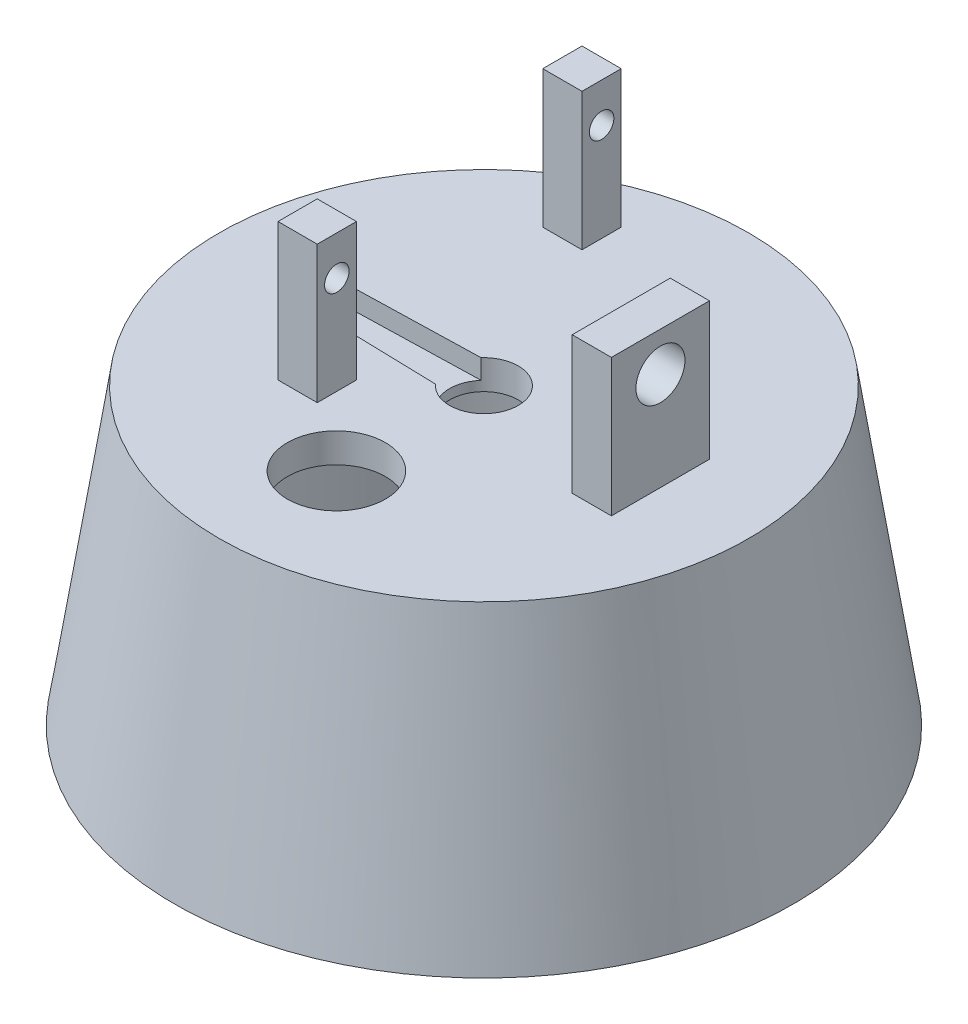
from build123d import *

# Parameters (mm, degrees)
SKETCH_1_R          = 27
SKETCH_1_R_2        = 25.25
EXTRUDE_1_DEPTH     = 27
SKETCH_3_R          = 27
SKETCH_3_R_2        = 2.4
EXTRUDE_2_DEPTH     = 3
SKETCH_7_W          = 4
SKETCH_7_H          = 4
EXTRUDE_3_DEPTH     = 14
SKETCH_8_R          = 1.25
CUT_EXTRUDE_1_DEPTH = 14
SKETCH_10_W         = 4
SKETCH_10_H         = 10
EXTRUDE_4_DEPTH     = 14
SKETCH_11_R         = 2.5
CUT_EXTRUDE_3_DEPTH = 14
SKETCH_12_R         = 5
CUT_EXTRUDE_4_DEPTH = 14
SKETCH_13_R         = 2.4
CUT_EXTRUDE_5_DEPTH = 2
SKETCH_14_R         = 2.4
CUT_EXTRUDE_6_DEPTH = 91


with BuildPart() as part:
    # 草图1 → 凸台-拉伸1 (new body)
    with BuildSketch(Plane(origin=(0, 0, 0), x_dir=(1, 0, 0), z_dir=(0, 1, 0))):
        Circle(SKETCH_1_R)
        Circle(SKETCH_1_R_2, mode=Mode.SUBTRACT)
    extrude(amount=EXTRUDE_1_DEPTH)

    # 草图3 → 凸台-拉伸2 (add)
    with BuildSketch(Plane(origin=(0, 27, 0), x_dir=(1, 0, 0), z_dir=(0, 1, 0))):
        Circle(SKETCH_3_R)
        Circle(SKETCH_3_R_2, mode=Mode.SUBTRACT)
    extrude(amount=EXTRUDE_2_DEPTH)

    # 草图5 → 旋转2 (revolve)
    with BuildSketch(Plane.XY):
        Polygon((27, 30), (31.564027788, 0), (27, 0), align=None)
    revolve(axis=Axis((0, 0, 0), (0, 1, 0)))

    # 草图7 → 凸台-拉伸3 (add)
    with BuildSketch(Plane(origin=(0, 30, 0), x_dir=(1, 0, 0), z_dir=(0, 1, 0))):
        with Locations((-9, 19)):
            Rectangle(SKETCH_7_W, SKETCH_7_H)
        with Locations((-9, -8)):
            Rectangle(SKETCH_7_W, SKETCH_7_H)
    extrude(amount=EXTRUDE_3_DEPTH)

    # 草图8 → 切除-拉伸1 (cut)
    with BuildSketch(Plane(origin=(-7, 0, 0), x_dir=(0, 0, -1), z_dir=(1, 0, 0))):
        with Locations((-8, 40)):
            Circle(SKETCH_8_R)
        with Locations((19, 40)):
            Circle(SKETCH_8_R)
    extrude(amount=-CUT_EXTRUDE_1_DEPTH, mode=Mode.SUBTRACT)

    # 草图10 → 凸台-拉伸4 (add)
    with BuildSketch(Plane(origin=(0, 30, 0), x_dir=(1, 0, 0), z_dir=(0, 1, 0))):
        with Locations((16, 0)):
            Rectangle(SKETCH_10_W, SKETCH_10_H)
    extrude(amount=EXTRUDE_4_DEPTH)

    # 草图11 → 切除-拉伸3 (cut)
    with BuildSketch(Plane(origin=(18, 0, 0), x_dir=(0, 0, -1), z_dir=(1, 0, 0))):
        with Locations((0, 40)):
            Circle(SKETCH_11_R)
    extrude(amount=-CUT_EXTRUDE_3_DEPTH, mode=Mode.SUBTRACT)

    # 草图12 → 切除-拉伸4 (cut)
    with BuildSketch(Plane(origin=(0, 30, 0), x_dir=(1, 0, 0), z_dir=(0, 1, 0))):
        with Locations((0, -15.04505665)):
            Circle(SKETCH_12_R)
    extrude(amount=-CUT_EXTRUDE_4_DEPTH, mode=Mode.SUBTRACT)

    # 草图13 → 切除-拉伸5 (cut)
    with BuildSketch(Plane(origin=(0, 30, 0), x_dir=(1, 0, 0), z_dir=(0, 1, 0))):
        with BuildLine():
            Line((-2.610752853, 2.331087631), (-15, 2))
            ThreePointArc((-15, 2), (-16.999822183, 0.026669038), (-15.053333333, -1.999288762))
            Line((-15.053333333, -1.999288762), (-2.610641885, -2.331211906))
            ThreePointArc((-2.610641885, -2.331211906), (3.499999999, 8.3304e-05), (-2.610752853, 2.331087631))
        make_face()
        Circle(SKETCH_13_R, mode=Mode.SUBTRACT)
    extrude(amount=-CUT_EXTRUDE_5_DEPTH, mode=Mode.SUBTRACT)

    # 草图14 → 切除-拉伸6 (cut)
    with BuildSketch(Plane(origin=(0, 28, 0), x_dir=(1, 0, 0), z_dir=(0, 1, 0))):
        with BuildLine():
            ThreePointArc((-2.610752853, 2.331087631), (-3.499999999, -8.3304e-05), (-2.610641885, -2.331211906))
            ThreePointArc((-2.610641885, -2.331211906), (1.247548276, -3.270110594), (3.5, 0))
            ThreePointArc((3.5, 0), (1.247470444, 3.270140286), (-2.610752853, 2.331087631))
        make_face()
        Circle(SKETCH_14_R, mode=Mode.SUBTRACT)
    extrude(amount=-CUT_EXTRUDE_6_DEPTH, mode=Mode.SUBTRACT)


solid = part.part
